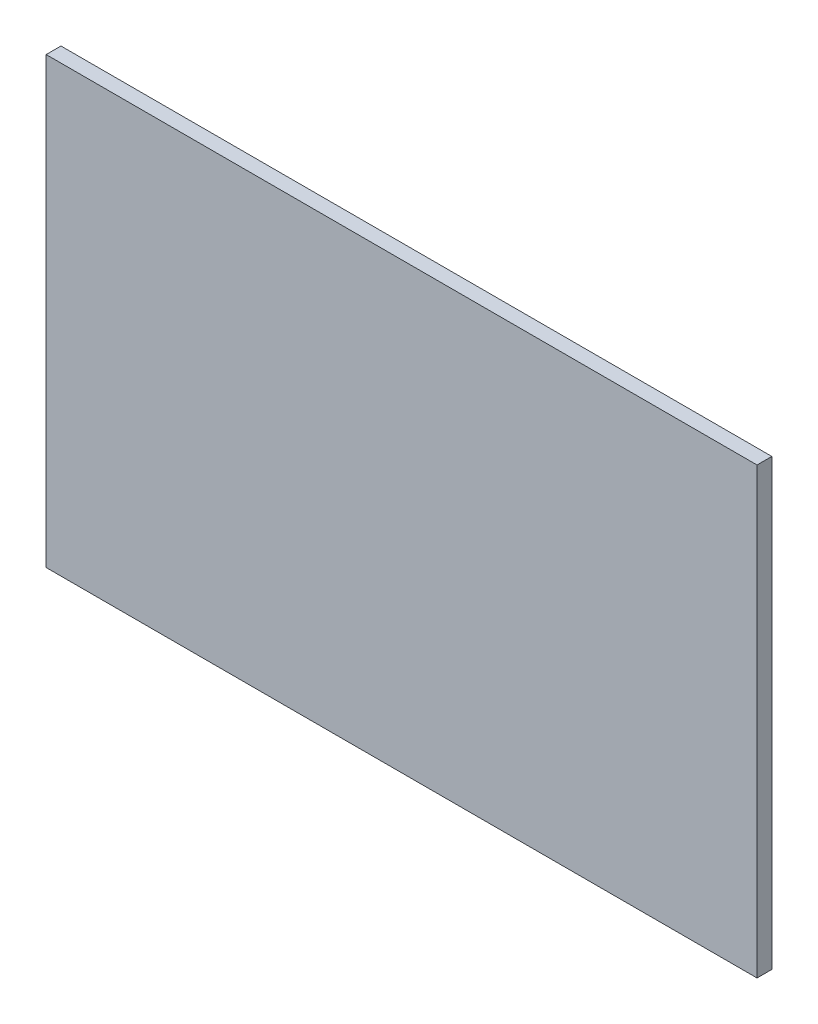
from build123d import *

# Parameters (mm, degrees)
SKETCH1_W           = 240
SKETCH1_H           = 150
BOSS_EXTRUDE1_DEPTH = 5


with BuildPart() as part:
    # Sketch1 → Boss-Extrude1 (new body)
    with BuildSketch(Plane.XY):
        Rectangle(SKETCH1_W, SKETCH1_H)
    extrude(amount=BOSS_EXTRUDE1_DEPTH)


solid = part.part
